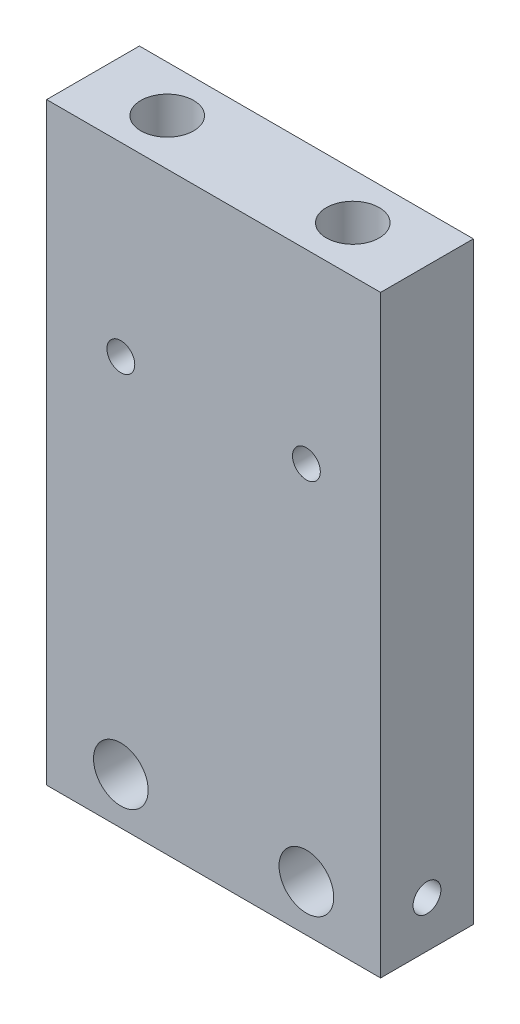
from build123d import *

# Parameters (mm, degrees)
SKETCH1_W      = 18
SKETCH1_H      = 32
EXTRUDE1_DEPTH = 5
SKETCH3_R      = 0.75
SKETCH3_R_2    = 1.4732
EXTRUDE2_DEPTH = 6
SKETCH4_R      = 0.75
EXTRUDE3_DEPTH = 2.794


with BuildPart() as part:
    # Sketch1 → Extrude1 (new body)
    with BuildSketch(Plane.XY):
        with Locations((-9, 16)):
            Rectangle(SKETCH1_W, SKETCH1_H)
    extrude(amount=EXTRUDE1_DEPTH)

    # Sketch2 → #4-40 Tapped Hole1 (revolve, cut)
    with BuildSketch(Plane(origin=(-14, 32, 2.5), x_dir=(0, 0, 1), z_dir=(1, 0, 0))):
        Polygon((0, 0), (0, 10.813752758), (1.1303, 10.1346), (1.1303, 8.2296), (1.4224, 8.2296), (1.4224, 0), align=None)
    f_4_40_tapped_hole1 = revolve(axis=Axis((-14, 38.35, 2.5), (0, -1, 0)), mode=Mode.SUBTRACT)

    # Sketch3 → Extrude2 (cut, through all)
    with BuildSketch(Plane.XY.offset(5)):
        with Locations((-14, 22)):
            Circle(SKETCH3_R)
        with Locations((-14, 2.5)):
            Circle(SKETCH3_R_2)
    extrude2 = extrude(amount=-EXTRUDE2_DEPTH, mode=Mode.SUBTRACT)

    # Sketch4 → Extrude3 (cut)
    with BuildSketch(Plane.ZY.offset(18)):
        with Locations((2.5, 2.5)):
            Circle(SKETCH4_R)
    extrude3 = extrude(amount=-EXTRUDE3_DEPTH, mode=Mode.SUBTRACT)

    # Mirror2: #4-40 Tapped Hole1, Extrude2, Extrude3 across plane
    add(f_4_40_tapped_hole1.mirror(Plane(origin=(-9, 0, 0), x_dir=(0, 0, 1), z_dir=(1, 0, 0))), mode=Mode.SUBTRACT)
    add(extrude2.mirror(Plane(origin=(-9, 0, 0), x_dir=(0, 0, 1), z_dir=(1, 0, 0))), mode=Mode.SUBTRACT)
    add(extrude3.mirror(Plane(origin=(-9, 0, 0), x_dir=(0, 0, 1), z_dir=(1, 0, 0))), mode=Mode.SUBTRACT)


solid = part.part
